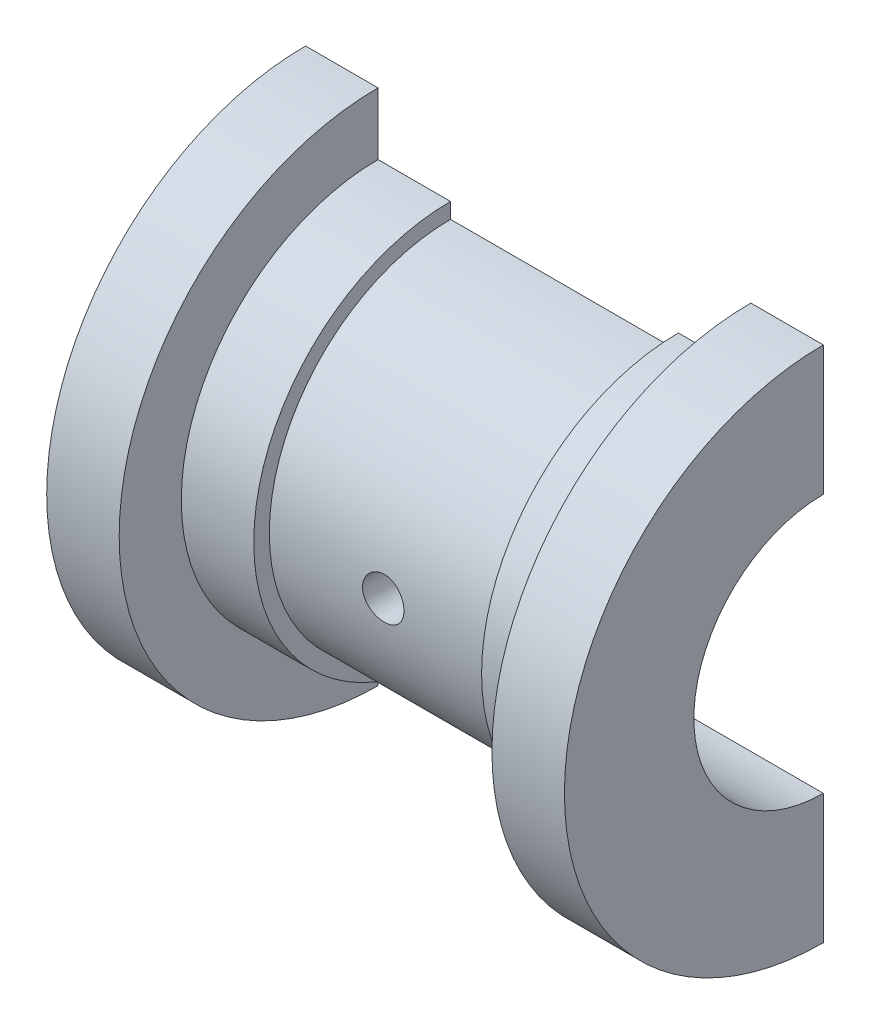
from build123d import *

# Parameters (mm, degrees)
REVOLVE1_ANGLE     = 180
CUT_EXTRUDE3_DEPTH = 50
SKETCH4_R          = 2
CUT_EXTRUDE4_DEPTH = 43


with BuildPart() as part:
    # Sketch1 → Revolve1 (revolve)
    with BuildSketch(Plane.XY):
        Polygon((25, 0), (-25, 0), (-25, 25), (-18, 25), (-18, 19), (-11, 19), (-11, 17.5), (11, 17.5), (11, 19), (18, 19), (18, 25), (25, 25), align=None)
    revolve(axis=Axis((-38.949360705, 0, 0), (1, 0, 0)), revolution_arc=REVOLVE1_ANGLE)

    # Sketch2 → Cut-Extrude3 (cut)
    with BuildSketch(Plane.ZY.offset(25)):
        with BuildLine():
            Line((0, 12.5), (0, -12.5))
            ThreePointArc((0, -12.5), (12.5, 0), (0, 12.5))
        make_face()
    extrude(amount=-CUT_EXTRUDE3_DEPTH, mode=Mode.SUBTRACT)

    # Sketch4 → Cut-Extrude4 (cut)
    with BuildSketch(Plane(origin=(0, 0, 17.5), x_dir=(-1, 0, 0), z_dir=(0, 0, -1))):
        Circle(SKETCH4_R)
    extrude(amount=CUT_EXTRUDE4_DEPTH, mode=Mode.SUBTRACT)


solid = part.part
